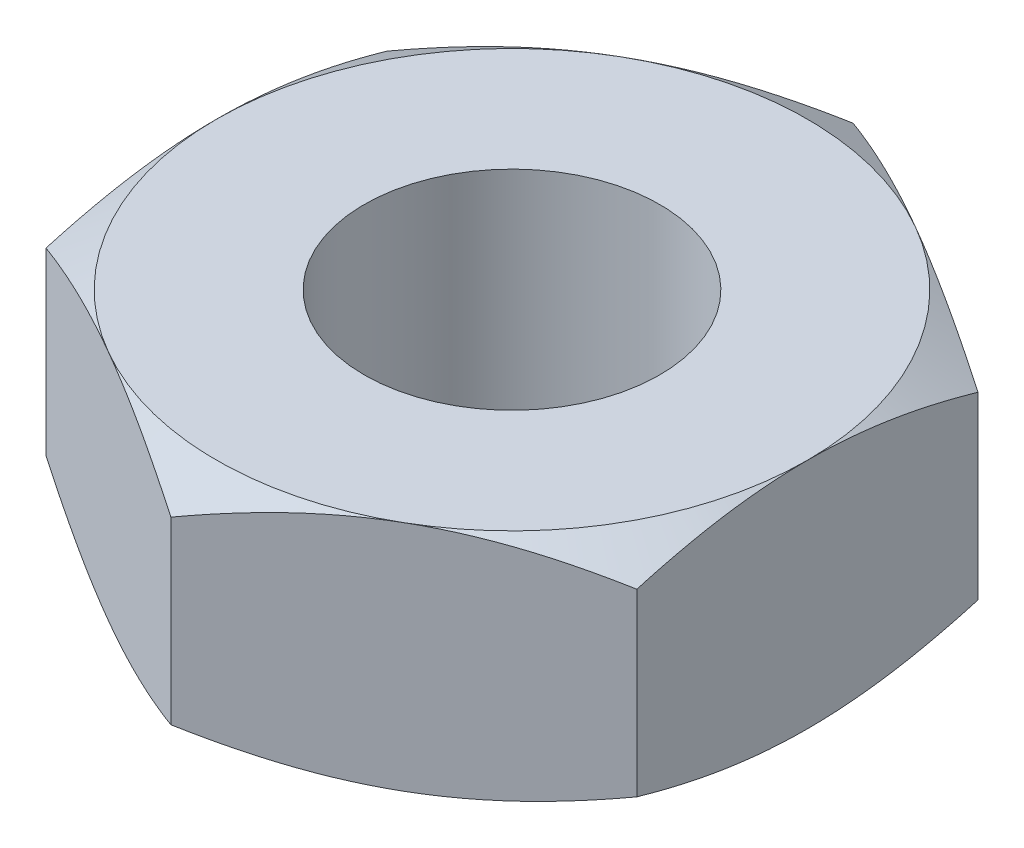
from build123d import *

# Parameters (mm, degrees)
SKETCH1_R           = 6.35
BOSS_EXTRUDE1_DEPTH = 5


with BuildPart() as part:
    # Sketch1 → Boss-Extrude1 (new body, symmetric)
    with BuildSketch(Plane(origin=(0, 0, 0), x_dir=(1, 0, 0), z_dir=(0, 1, 0))):
        Polygon((12.7, 7.332348419), (0, 14.664696837), (-12.7, 7.332348419), (-12.7, -7.332348419), (0, -14.664696837), (12.7, -7.332348419), align=None)
        Circle(SKETCH1_R, mode=Mode.SUBTRACT)
    extrude(amount=BOSS_EXTRUDE1_DEPTH, both=True)

    # Sketch2 → Cut-Revolve1 (revolve, cut)
    with BuildSketch(Plane.XY):
        Polygon((12.7, 5), (15.7, 5), (15.7, 3.267949192), align=None)
        Polygon((12.7, -5), (15.7, -5), (15.7, -3.267949192), align=None)
    revolve(axis=Axis((0, 0, 0), (0, 1, 0)), mode=Mode.SUBTRACT)


solid = part.part
